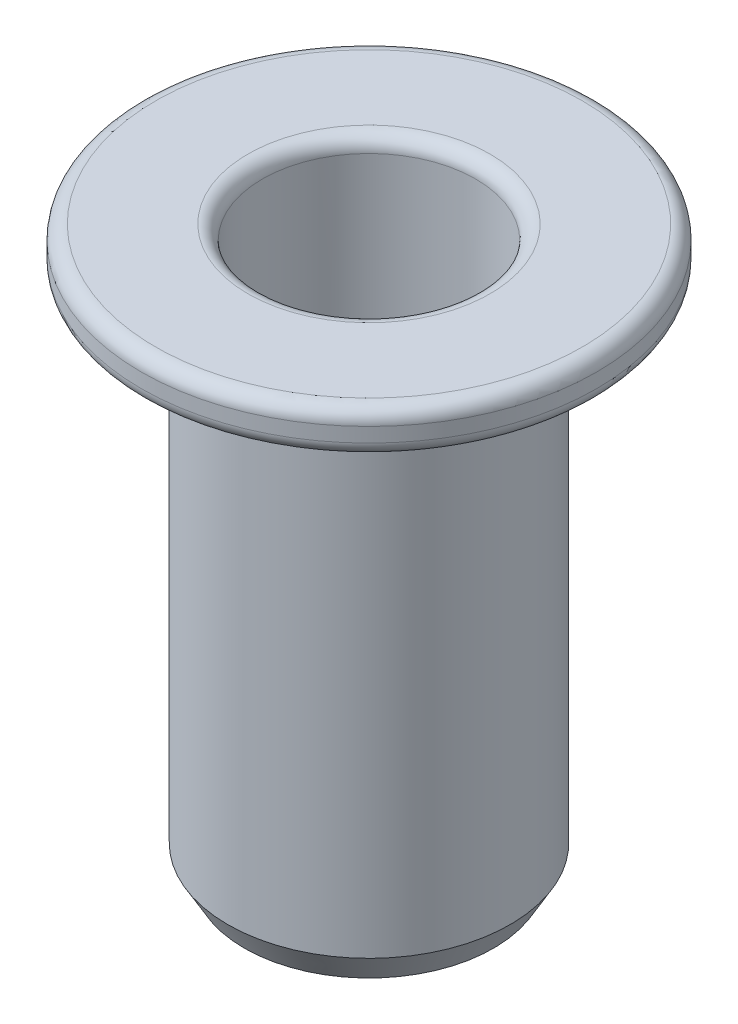
from build123d import *

# Parameters (mm, degrees)
FILLET1_R      = 0.25
CHAMFER1_SIZE  = 0.5
CHAMFER1_SIZE2 = 0.288675135
CHAMFER2_SIZE  = 0.5


with BuildPart() as part:
    # Sketch1 → Revolve1 (revolve)
    with BuildSketch(Plane.XY):
        Polygon((1.85, 0), (1.85, -4.5), (1.5, -4.5), (1.5, -9.8), (2.45, -9.8), (2.45, -0.75), (3.95, -0.75), (3.95, 0), align=None)
    revolve(axis=Axis((0, 0, 0), (0, -1, 0)))

    # Fillet1
    fillet1_edges = [part.edges().sort_by_distance(p)[0] for p in [
        (-3.95, 0, 0),
        (-3.95, -0.75, 0),
        (-1.85, 0, 0),
    ]]
    fillet(fillet1_edges, radius=FILLET1_R)

    # Chamfer1
    chamfer1_edges = [part.edges().sort_by_distance(p)[0] for p in [
        (-2.45, -9.8, 0),
    ]]
    chamfer1_side = [part.faces().sort_by_distance(p)[0] for p in [
        (-2.45, -5.275, 0),
    ]]
    chamfer(chamfer1_edges, length=CHAMFER1_SIZE, length2=CHAMFER1_SIZE2, reference=chamfer1_side[0])

    # Chamfer2
    chamfer2_edges = [part.edges().sort_by_distance(p)[0] for p in [
        (-1.5, -9.8, 0),
    ]]
    chamfer(chamfer2_edges, length=CHAMFER2_SIZE)


solid = part.part
